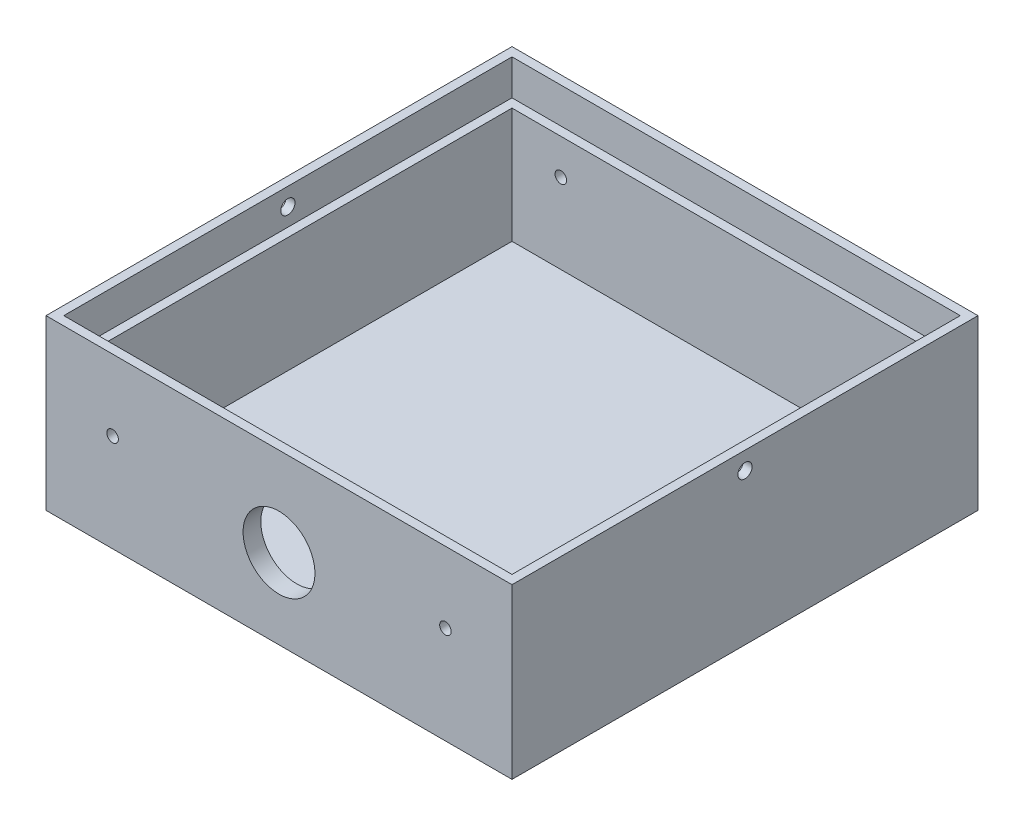
from build123d import *

# Parameters (mm, degrees)
SKETCH1_W           = 105
SKETCH1_H           = 105
BOSS_EXTRUDE1_DEPTH = 38
SKETCH2_W           = 97
SKETCH2_H           = 97
CUT_EXTRUDE1_DEPTH  = 34
SKETCH3_W           = 101
SKETCH3_H           = 101
CUT_EXTRUDE2_DEPTH  = 8
SKETCH5_R           = 1.6
CUT_EXTRUDE3_DEPTH  = 106
SKETCH6_R           = 2.75
BOSS_EXTRUDE2_DEPTH = 3
FILLET1_R           = 4
CUT_EXTRUDE4_REACH  = 6
SKETCH7_R           = 8.1
CUT_EXTRUDE5_DEPTH  = 1
SKETCH11_R          = 1.3
CUT_EXTRUDE6_DEPTH  = 106


with BuildPart() as part:
    # Sketch1 → Boss-Extrude1 (new body)
    with BuildSketch(Plane(origin=(0, 0, 0), x_dir=(1, 0, 0), z_dir=(0, 1, 0))):
        Rectangle(SKETCH1_W, SKETCH1_H)
    extrude(amount=BOSS_EXTRUDE1_DEPTH)

    # Sketch2 → Cut-Extrude1 (cut)
    with BuildSketch(Plane(origin=(0, 38, 0), x_dir=(1, 0, 0), z_dir=(0, 1, 0))):
        Rectangle(SKETCH2_W, SKETCH2_H)
    extrude(amount=-CUT_EXTRUDE1_DEPTH, mode=Mode.SUBTRACT)

    # Sketch3 → Cut-Extrude2 (cut)
    with BuildSketch(Plane(origin=(0, 38, 0), x_dir=(1, 0, 0), z_dir=(0, 1, 0))):
        Rectangle(SKETCH3_W, SKETCH3_H)
    extrude(amount=-CUT_EXTRUDE2_DEPTH, mode=Mode.SUBTRACT)

    # Sketch5 → Cut-Extrude3 (cut, through all)
    with BuildSketch(Plane(origin=(52.5, 0, 0), x_dir=(0, 0, -1), z_dir=(1, 0, 0))):
        with Locations((0, 34)):
            Circle(SKETCH5_R)
    extrude(amount=-CUT_EXTRUDE3_DEPTH, mode=Mode.SUBTRACT)

    # Sketch6 → Boss-Extrude2 (add)
    with BuildSketch(Plane(origin=(0, 0, -52.5), x_dir=(-1, 0, 0), z_dir=(0, 0, -1))):
        with BuildLine():
            Line((-12, 0), (12, 0))
            Line((12, 0), (12, -5))
            Line((12, -5), (12, -17))
            ThreePointArc((12, -17), (0, -29), (-12, -17))
            Line((-12, -17), (-12, -5))
            Line((-12, -5), (-12, 0))
        make_face()
        with Locations((0, -17)):
            Circle(SKETCH6_R, mode=Mode.SUBTRACT)
    extrude(amount=-BOSS_EXTRUDE2_DEPTH)

    # Fillet1
    fillet1_edges = [part.edges().sort_by_distance(p)[0] for p in [
        (0, 0, -49.5),
        (12, 0, -51),
        (-12, 0, -51),
    ]]
    fillet(fillet1_edges, radius=FILLET1_R)

    # Sketch7 → Cut-Extrude4 (cut, up to next)
    with BuildSketch(Plane(origin=(0, 0, 48.5), x_dir=(-1, 0, 0), z_dir=(0, 0, -1)), mode=Mode.PRIVATE) as cut_extrude4_sk1:
        with Locations((0, 18)):
            Circle(SKETCH7_R)
    cut_extrude4_tool1 = extrude(cut_extrude4_sk1.sketch, amount=-CUT_EXTRUDE4_REACH, mode=Mode.PRIVATE) & part.part
    add(cut_extrude4_tool1.solids().sort_by_distance((0, 18, 48.5))[0], mode=Mode.SUBTRACT)

    # Sketch10 → Cut-Extrude5 (cut)
    with BuildSketch(Plane.XZ):
        with BuildLine():
            Line((5, -10), (0, -10))
            ThreePointArc((0, -10), (-5, -5), (0, 0))
            ThreePointArc((0, 0), (-5, 5), (0, 10))
            Line((0, 10), (5, 10))
            Line((5, 10), (5, -10))
        make_face()
        with BuildLine():
            Line((0, -7), (2, -7))
            Line((2, -7), (2, -3))
            Line((2, -3), (0, -3))
            ThreePointArc((0, -3), (-2, -5), (0, -7))
        make_face(mode=Mode.SUBTRACT)
        with BuildLine():
            Line((0, 3), (2, 3))
            Line((2, 3), (2, 7))
            Line((2, 7), (0, 7))
            ThreePointArc((0, 7), (-2, 5), (0, 3))
        make_face(mode=Mode.SUBTRACT)
    extrude(amount=-CUT_EXTRUDE5_DEPTH, mode=Mode.SUBTRACT)

    # Sketch11 → Cut-Extrude6 (cut, through all)
    with BuildSketch(Plane.XY.offset(52.5)):
        with Locations((-37.5, 22)):
            Circle(SKETCH11_R)
        with Locations((37.5, 22)):
            Circle(SKETCH11_R)
    extrude(amount=-CUT_EXTRUDE6_DEPTH, mode=Mode.SUBTRACT)


solid = part.part
